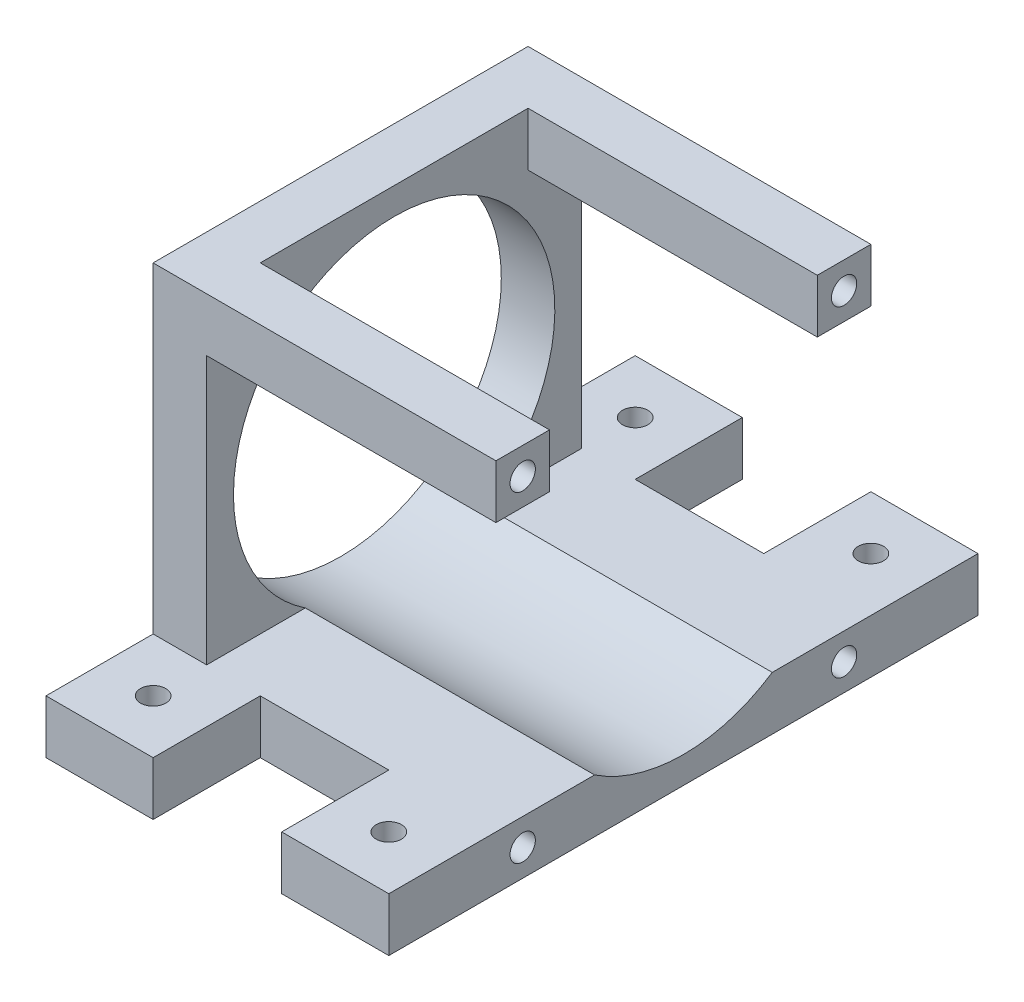
from build123d import *

# Parameters (mm, degrees)
SKETCH1_W           = 40.64
SKETCH1_H           = 44.45
BOSS_EXTRUDE1_DEPTH = 44.45
SKETCH4_R           = 19.05
CUT_EXTRUDE3_DEPTH  = 75.854623104
SKETCH5_W           = 34.29
SKETCH5_H           = 38.1
CUT_EXTRUDE4_DEPTH  = 75.854623104
SKETCH6_W           = 6.35
SKETCH6_H           = 6.35
BOSS_EXTRUDE2_DEPTH = 34.29
SKETCH7_R           = 1.5
CUT_EXTRUDE5_DEPTH  = 6.35
SKETCH8_W           = 12.7
SKETCH8_H           = 6.35
BOSS_EXTRUDE3_DEPTH = 12.7
SKETCH10_R          = 1.5
CUT_EXTRUDE6_DEPTH  = 12.7


with BuildPart() as part:
    # Sketch1 → Boss-Extrude1 (new body)
    with BuildSketch(Plane(origin=(0, 0, 0), x_dir=(1, 0, 0), z_dir=(0, 1, 0))):
        with Locations((20.32, 22.225)):
            Rectangle(SKETCH1_W, SKETCH1_H)
    extrude(amount=BOSS_EXTRUDE1_DEPTH)

    # Sketch4 → Cut-Extrude3 (cut, through all)
    with BuildSketch(Plane.ZY):
        with Locations((-22.225, 22.225)):
            Circle(SKETCH4_R)
    extrude(amount=-CUT_EXTRUDE3_DEPTH, mode=Mode.SUBTRACT)

    # Sketch5 → Cut-Extrude4 (cut, through all)
    with BuildSketch(Plane(origin=(0, 0, -44.45), x_dir=(-1, 0, 0), z_dir=(0, 0, -1))):
        with Locations((-23.495, 25.4)):
            Rectangle(SKETCH5_W, SKETCH5_H)
    extrude(amount=-CUT_EXTRUDE4_DEPTH, mode=Mode.SUBTRACT)

    # Sketch6 → Boss-Extrude2 (add)
    with BuildSketch(Plane(origin=(6.35, 0, 0), x_dir=(0, 0, -1), z_dir=(1, 0, 0))):
        with Locations((3.175, 41.275)):
            Rectangle(SKETCH6_W, SKETCH6_H)
        with Locations((41.275, 41.275)):
            Rectangle(SKETCH6_W, SKETCH6_H)
    extrude(amount=BOSS_EXTRUDE2_DEPTH)

    # Sketch7 → Cut-Extrude5 (cut)
    with BuildSketch(Plane(origin=(40.64, 0, 0), x_dir=(0, 0, -1), z_dir=(1, 0, 0))):
        with Locations((3.175, 41.275)):
            Circle(SKETCH7_R)
        with Locations((41.275, 41.275)):
            Circle(SKETCH7_R)
        with Locations((41.275, 3.175)):
            Circle(SKETCH7_R)
        with Locations((3.175, 3.175)):
            Circle(SKETCH7_R)
    extrude(amount=-CUT_EXTRUDE5_DEPTH, mode=Mode.SUBTRACT)

    # Sketch8 → Boss-Extrude3 (add)
    with BuildSketch(Plane(origin=(0, 0, -44.45), x_dir=(-1, 0, 0), z_dir=(0, 0, -1))):
        with Locations((-34.29, 3.175)):
            Rectangle(SKETCH8_W, SKETCH8_H)
        with Locations((-6.35, 3.175)):
            Rectangle(SKETCH8_W, SKETCH8_H)
    boss_extrude3 = extrude(amount=BOSS_EXTRUDE3_DEPTH)

    # Sketch10 → Cut-Extrude6 (cut)
    with BuildSketch(Plane(origin=(0, 6.35, 0), x_dir=(1, 0, 0), z_dir=(0, 1, 0))):
        with Locations((6.35, 50.8)):
            Circle(SKETCH10_R)
        with Locations((34.29, 50.8)):
            Circle(SKETCH10_R)
    cut_extrude6 = extrude(amount=-CUT_EXTRUDE6_DEPTH, mode=Mode.SUBTRACT)

    # Mirror1: Boss-Extrude3, Cut-Extrude6 across plane
    add(boss_extrude3.mirror(Plane(origin=(0, 0, -22.225), x_dir=(1, 0, 0), z_dir=(0, 0, -1))))
    add(cut_extrude6.mirror(Plane(origin=(0, 0, -22.225), x_dir=(1, 0, 0), z_dir=(0, 0, -1))), mode=Mode.SUBTRACT)


solid = part.part
